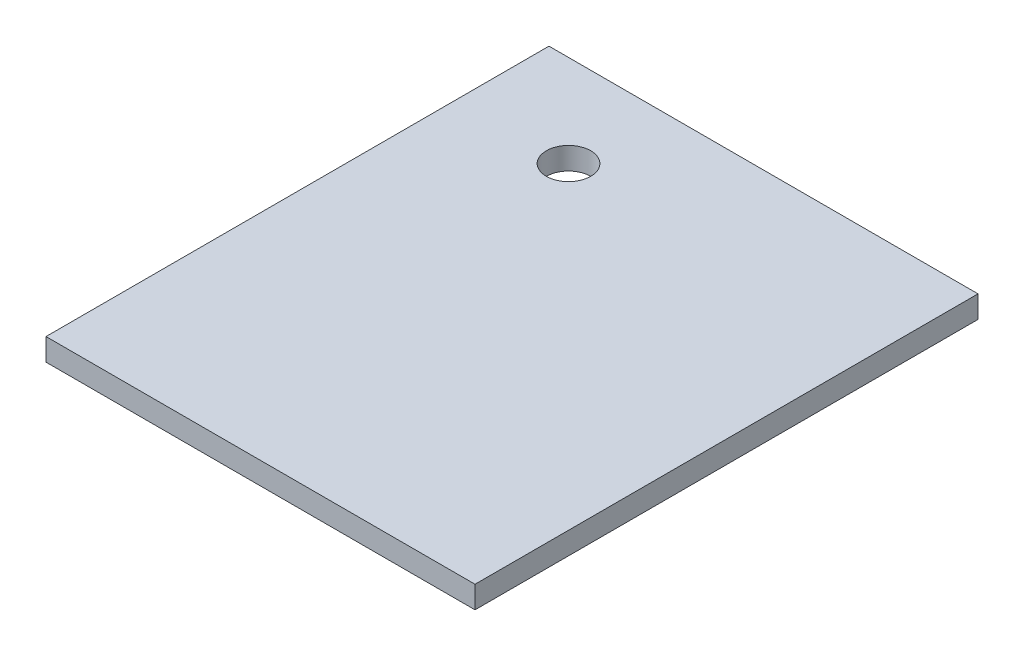
from build123d import *

# Parameters (mm, degrees)
SKETCH1_W                 = 58
SKETCH1_H                 = 68
BOSS_EXTRUDE1_DEPTH       = 3
F_6_0MM_DOWEL_HOLE1_D     = 6
F_6_0MM_DOWEL_HOLE1_DEPTH = 3


with BuildPart() as part:
    # Sketch1 → Boss-Extrude1 (new body)
    with BuildSketch(Plane(origin=(0, 0, 0), x_dir=(1, 0, 0), z_dir=(0, 1, 0))):
        with Locations((2.631421053, -22.558871845)):
            Rectangle(SKETCH1_W, SKETCH1_H)
    extrude(amount=BOSS_EXTRUDE1_DEPTH)

    # Ø6.0mm Dowel Hole1
    with Locations(Plane(origin=(0, 0, 0), x_dir=(-1, 0, 0), z_dir=(0, -1, 0))):
        with Locations((11.303876488, -0.981472803)):
            Hole(F_6_0MM_DOWEL_HOLE1_D / 2, depth=F_6_0MM_DOWEL_HOLE1_DEPTH)


solid = part.part
